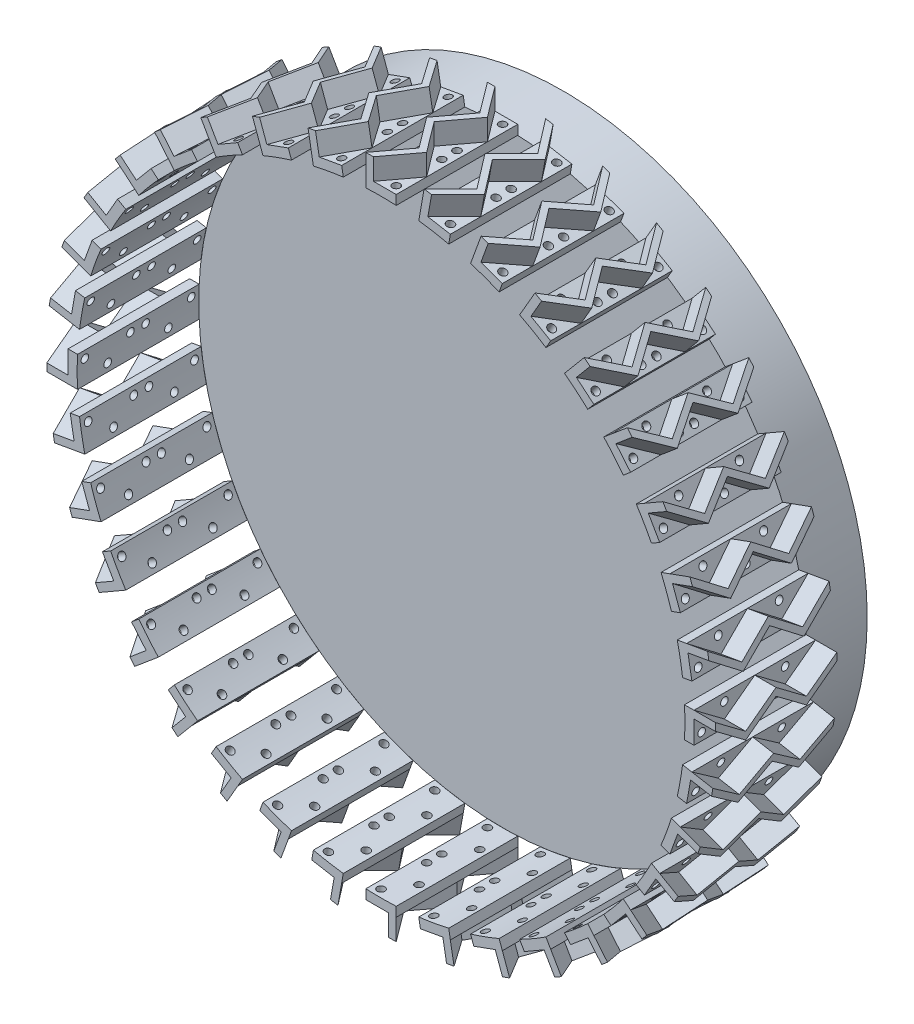
from build123d import *

# Parameters (mm, degrees)
SKETCH1_R           = 127
BOSS_EXTRUDE1_DEPTH = 50.8
SKETCH2_W           = 25.4
SKETCH2_H           = 12.7
SKETCH2_R           = 1.5875
BOSS_EXTRUDE2_DEPTH = 15.24
SKETCH2_4_R         = 1.5875
CUT_EXTRUDE1_DEPTH  = 8.89
LPATTERN1_COUNT     = 2
LPATTERN1_PITCH     = 25.4
SKETCH1_2_R         = 127
CUT_EXTRUDE2_DEPTH  = 101.6
SKETCH1_3_R         = 127
BOSS_EXTRUDE3_DEPTH = 25.4
CIRPATTERN1_COUNT   = 36


with BuildPart() as part:
    # Sketch1 → Boss-Extrude1 (new body)
    with BuildSketch(Plane.XY):
        Circle(SKETCH1_R)
    extrude(amount=BOSS_EXTRUDE1_DEPTH)


with BuildPart() as body_2:
    # Sketch2 → Boss-Extrude2 (new body)
    with BuildSketch(Plane(origin=(139.7, 0, 0), x_dir=(0, 0, -1), z_dir=(1, 0, 0))):
        with Locations((-12.7, 0)):
            Rectangle(SKETCH2_W, SKETCH2_H)
        with Locations((-3.175, -3.175)):
            Circle(SKETCH2_R, mode=Mode.SUBTRACT)
        with Locations((-22.225, -3.175)):
            Circle(SKETCH2_R, mode=Mode.SUBTRACT)
        with Locations((-12.7, 3.175)):
            Circle(SKETCH2_R, mode=Mode.SUBTRACT)
    extrude(amount=-BOSS_EXTRUDE2_DEPTH)

    # Sketch2_4 → Cut-Extrude1 (cut)
    # profile 1 of 3: a face of its own
    with BuildSketch(Plane(origin=(139.7, 0, 0), x_dir=(0, 0, -1), z_dir=(1, 0, 0))):
        Polygon((0, -6.35), (0, 3.175), (-12.7, -6.35), align=None)
        with Locations((-3.175, -3.175)):
            Circle(SKETCH2_4_R, mode=Mode.SUBTRACT)
    # profile 2 of 3: a face of its own
    with BuildSketch(Plane(origin=(139.7, 0, 0), x_dir=(0, 0, -1), z_dir=(1, 0, 0))):
        Polygon((-12.7, -3.175), (0, 6.35), (-25.4, 6.35), align=None)
        with Locations((-12.7, 3.175)):
            Circle(SKETCH2_4_R, mode=Mode.SUBTRACT)
    # profile 3 of 3: a face of its own
    with BuildSketch(Plane(origin=(139.7, 0, 0), x_dir=(0, 0, -1), z_dir=(1, 0, 0))):
        Polygon((-25.4, -6.35), (-12.7, -6.35), (-25.4, 3.175), align=None)
        with Locations((-22.225, -3.175)):
            Circle(SKETCH2_4_R, mode=Mode.SUBTRACT)
    extrude(amount=-CUT_EXTRUDE1_DEPTH, mode=Mode.SUBTRACT)


with BuildPart() as lpattern1_1:
    # LPattern1: pattern copy
    add(body_2.part.moved(Location(Vector(0, 0, 1) * (1 * LPATTERN1_PITCH))))

    # Combine1: union body 2
    add(body_2.part)


with BuildPart() as cut_extrude2_tool:
    # Sketch1_2 → Cut-Extrude2 (new body)
    with BuildSketch(Plane.XY):
        Circle(SKETCH1_2_R)
    extrude(amount=CUT_EXTRUDE2_DEPTH)


with BuildPart() as part_1:
    add(part.part)

    # Cut-Extrude2: cut by cut_extrude2_tool
    add(cut_extrude2_tool.part, mode=Mode.SUBTRACT)


with BuildPart() as lpattern1_1_1:
    add(lpattern1_1.part)

    # Cut-Extrude2: cut by cut_extrude2_tool
    add(cut_extrude2_tool.part, mode=Mode.SUBTRACT)


with BuildPart() as body_2_2:
    # Sketch1_3 → Boss-Extrude3 (new body)
    with BuildSketch(Plane.XY):
        Circle(SKETCH1_3_R)
    extrude(amount=-BOSS_EXTRUDE3_DEPTH)


with BuildPart() as cirpattern1_1:
    # CirPattern1: pattern copy
    add(lpattern1_1_1.part.rotate(Axis((0, 0, 0), (0, 0, 1)), 1 * 360 / CIRPATTERN1_COUNT))


with BuildPart() as cirpattern1_2:
    # CirPattern1: pattern copy
    add(lpattern1_1_1.part.rotate(Axis((0, 0, 0), (0, 0, 1)), 2 * 360 / CIRPATTERN1_COUNT))


with BuildPart() as cirpattern1_3:
    # CirPattern1: pattern copy
    add(lpattern1_1_1.part.rotate(Axis((0, 0, 0), (0, 0, 1)), 3 * 360 / CIRPATTERN1_COUNT))


with BuildPart() as cirpattern1_4:
    # CirPattern1: pattern copy
    add(lpattern1_1_1.part.rotate(Axis((0, 0, 0), (0, 0, 1)), 4 * 360 / CIRPATTERN1_COUNT))


with BuildPart() as cirpattern1_5:
    # CirPattern1: pattern copy
    add(lpattern1_1_1.part.rotate(Axis((0, 0, 0), (0, 0, 1)), 5 * 360 / CIRPATTERN1_COUNT))


with BuildPart() as cirpattern1_6:
    # CirPattern1: pattern copy
    add(lpattern1_1_1.part.rotate(Axis((0, 0, 0), (0, 0, 1)), 6 * 360 / CIRPATTERN1_COUNT))


with BuildPart() as cirpattern1_7:
    # CirPattern1: pattern copy
    add(lpattern1_1_1.part.rotate(Axis((0, 0, 0), (0, 0, 1)), 7 * 360 / CIRPATTERN1_COUNT))


with BuildPart() as cirpattern1_8:
    # CirPattern1: pattern copy
    add(lpattern1_1_1.part.rotate(Axis((0, 0, 0), (0, 0, 1)), 8 * 360 / CIRPATTERN1_COUNT))


with BuildPart() as cirpattern1_9:
    # CirPattern1: pattern copy
    add(lpattern1_1_1.part.rotate(Axis((0, 0, 0), (0, 0, 1)), 9 * 360 / CIRPATTERN1_COUNT))


with BuildPart() as cirpattern1_10:
    # CirPattern1: pattern copy
    add(lpattern1_1_1.part.rotate(Axis((0, 0, 0), (0, 0, 1)), 10 * 360 / CIRPATTERN1_COUNT))


with BuildPart() as cirpattern1_11:
    # CirPattern1: pattern copy
    add(lpattern1_1_1.part.rotate(Axis((0, 0, 0), (0, 0, 1)), 11 * 360 / CIRPATTERN1_COUNT))


with BuildPart() as cirpattern1_12:
    # CirPattern1: pattern copy
    add(lpattern1_1_1.part.rotate(Axis((0, 0, 0), (0, 0, 1)), 12 * 360 / CIRPATTERN1_COUNT))


with BuildPart() as cirpattern1_13:
    # CirPattern1: pattern copy
    add(lpattern1_1_1.part.rotate(Axis((0, 0, 0), (0, 0, 1)), 13 * 360 / CIRPATTERN1_COUNT))


with BuildPart() as cirpattern1_14:
    # CirPattern1: pattern copy
    add(lpattern1_1_1.part.rotate(Axis((0, 0, 0), (0, 0, 1)), 14 * 360 / CIRPATTERN1_COUNT))


with BuildPart() as cirpattern1_15:
    # CirPattern1: pattern copy
    add(lpattern1_1_1.part.rotate(Axis((0, 0, 0), (0, 0, 1)), 15 * 360 / CIRPATTERN1_COUNT))


with BuildPart() as cirpattern1_16:
    # CirPattern1: pattern copy
    add(lpattern1_1_1.part.rotate(Axis((0, 0, 0), (0, 0, 1)), 16 * 360 / CIRPATTERN1_COUNT))


with BuildPart() as cirpattern1_17:
    # CirPattern1: pattern copy
    add(lpattern1_1_1.part.rotate(Axis((0, 0, 0), (0, 0, 1)), 17 * 360 / CIRPATTERN1_COUNT))


with BuildPart() as cirpattern1_18:
    # CirPattern1: pattern copy
    add(lpattern1_1_1.part.rotate(Axis((0, 0, 0), (0, 0, 1)), 18 * 360 / CIRPATTERN1_COUNT))


with BuildPart() as cirpattern1_19:
    # CirPattern1: pattern copy
    add(lpattern1_1_1.part.rotate(Axis((0, 0, 0), (0, 0, 1)), 19 * 360 / CIRPATTERN1_COUNT))


with BuildPart() as cirpattern1_20:
    # CirPattern1: pattern copy
    add(lpattern1_1_1.part.rotate(Axis((0, 0, 0), (0, 0, 1)), 20 * 360 / CIRPATTERN1_COUNT))


with BuildPart() as cirpattern1_21:
    # CirPattern1: pattern copy
    add(lpattern1_1_1.part.rotate(Axis((0, 0, 0), (0, 0, 1)), 21 * 360 / CIRPATTERN1_COUNT))


with BuildPart() as cirpattern1_22:
    # CirPattern1: pattern copy
    add(lpattern1_1_1.part.rotate(Axis((0, 0, 0), (0, 0, 1)), 22 * 360 / CIRPATTERN1_COUNT))


with BuildPart() as cirpattern1_23:
    # CirPattern1: pattern copy
    add(lpattern1_1_1.part.rotate(Axis((0, 0, 0), (0, 0, 1)), 23 * 360 / CIRPATTERN1_COUNT))


with BuildPart() as cirpattern1_24:
    # CirPattern1: pattern copy
    add(lpattern1_1_1.part.rotate(Axis((0, 0, 0), (0, 0, 1)), 24 * 360 / CIRPATTERN1_COUNT))


with BuildPart() as cirpattern1_25:
    # CirPattern1: pattern copy
    add(lpattern1_1_1.part.rotate(Axis((0, 0, 0), (0, 0, 1)), 25 * 360 / CIRPATTERN1_COUNT))


with BuildPart() as cirpattern1_26:
    # CirPattern1: pattern copy
    add(lpattern1_1_1.part.rotate(Axis((0, 0, 0), (0, 0, 1)), 26 * 360 / CIRPATTERN1_COUNT))


with BuildPart() as cirpattern1_27:
    # CirPattern1: pattern copy
    add(lpattern1_1_1.part.rotate(Axis((0, 0, 0), (0, 0, 1)), 27 * 360 / CIRPATTERN1_COUNT))


with BuildPart() as cirpattern1_28:
    # CirPattern1: pattern copy
    add(lpattern1_1_1.part.rotate(Axis((0, 0, 0), (0, 0, 1)), 28 * 360 / CIRPATTERN1_COUNT))


with BuildPart() as cirpattern1_29:
    # CirPattern1: pattern copy
    add(lpattern1_1_1.part.rotate(Axis((0, 0, 0), (0, 0, 1)), 29 * 360 / CIRPATTERN1_COUNT))


with BuildPart() as cirpattern1_30:
    # CirPattern1: pattern copy
    add(lpattern1_1_1.part.rotate(Axis((0, 0, 0), (0, 0, 1)), 30 * 360 / CIRPATTERN1_COUNT))


with BuildPart() as cirpattern1_31:
    # CirPattern1: pattern copy
    add(lpattern1_1_1.part.rotate(Axis((0, 0, 0), (0, 0, 1)), 31 * 360 / CIRPATTERN1_COUNT))


with BuildPart() as cirpattern1_32:
    # CirPattern1: pattern copy
    add(lpattern1_1_1.part.rotate(Axis((0, 0, 0), (0, 0, 1)), 32 * 360 / CIRPATTERN1_COUNT))


with BuildPart() as cirpattern1_33:
    # CirPattern1: pattern copy
    add(lpattern1_1_1.part.rotate(Axis((0, 0, 0), (0, 0, 1)), 33 * 360 / CIRPATTERN1_COUNT))


with BuildPart() as cirpattern1_34:
    # CirPattern1: pattern copy
    add(lpattern1_1_1.part.rotate(Axis((0, 0, 0), (0, 0, 1)), 34 * 360 / CIRPATTERN1_COUNT))


with BuildPart() as cirpattern1_35:
    # CirPattern1: pattern copy
    add(lpattern1_1_1.part.rotate(Axis((0, 0, 0), (0, 0, 1)), 35 * 360 / CIRPATTERN1_COUNT))


solid = Compound([lpattern1_1_1.part, body_2_2.part, cirpattern1_1.part, cirpattern1_2.part, cirpattern1_3.part, cirpattern1_4.part, cirpattern1_5.part, cirpattern1_6.part, cirpattern1_7.part, cirpattern1_8.part, cirpattern1_9.part, cirpattern1_10.part, cirpattern1_11.part, cirpattern1_12.part, cirpattern1_13.part, cirpattern1_14.part, cirpattern1_15.part, cirpattern1_16.part, cirpattern1_17.part, cirpattern1_18.part, cirpattern1_19.part, cirpattern1_20.part, cirpattern1_21.part, cirpattern1_22.part, cirpattern1_23.part, cirpattern1_24.part, cirpattern1_25.part, cirpattern1_26.part, cirpattern1_27.part, cirpattern1_28.part, cirpattern1_29.part, cirpattern1_30.part, cirpattern1_31.part, cirpattern1_32.part, cirpattern1_33.part, cirpattern1_34.part, cirpattern1_35.part])
